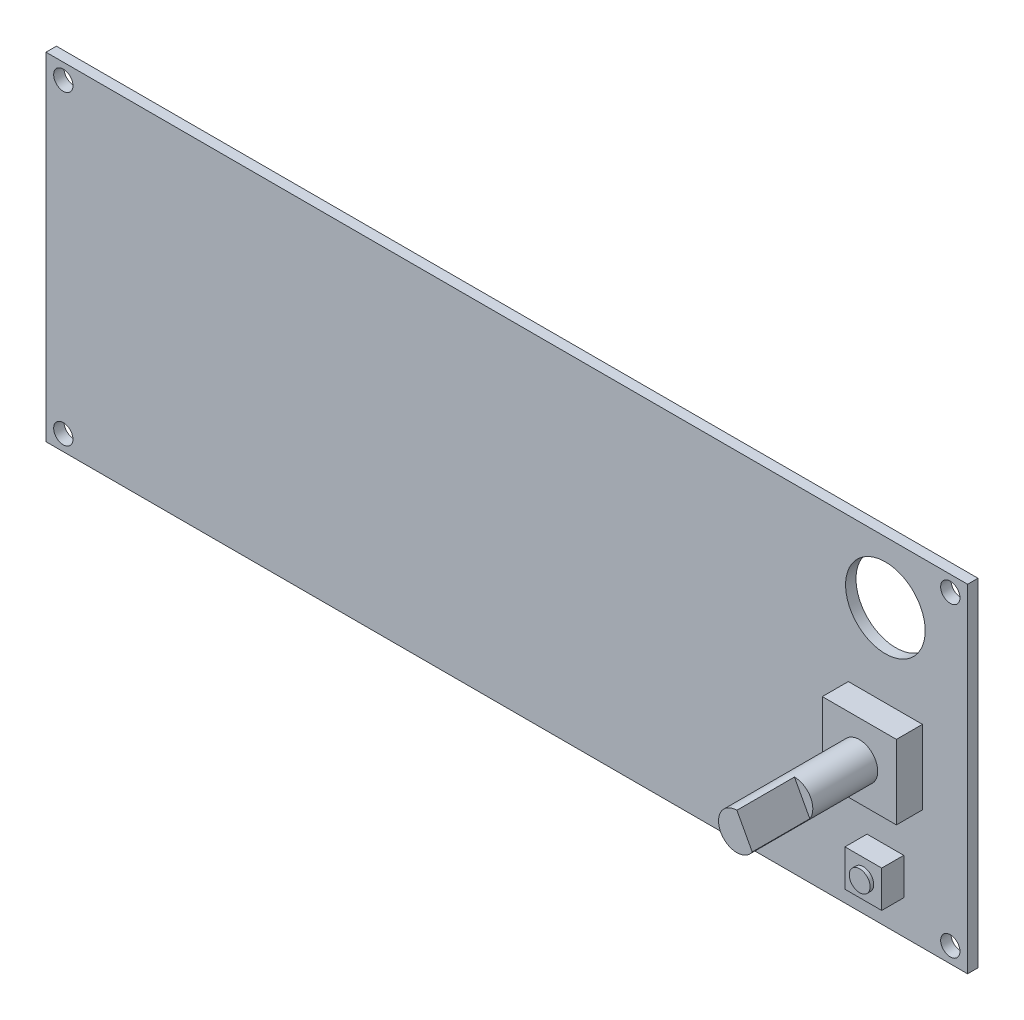
from build123d import *

# Parameters (mm, degrees)
SKETCH1_W                = 150.5
SKETCH1_H                = 55.1
SKETCH1_R                = 1.575
SKETCH1_R_2              = 6.5
SKETCH1_W_2              = 12.1
SKETCH1_H_2              = 12.1
SKETCH1_W_3              = 6
SKETCH1_H_3              = 6
BOSS_EXTRUDE1_DEPTH      = 1.7
SKETCH3_W                = 12.1
SKETCH3_H                = 12.1
BOSS_EXTRUDE2_DEPTH      = 4.25
BOSS_EXTRUDE2_DEPTH_BACK = 1.7
SKETCH5_R                = 3
BOSS_EXTRUDE3_DEPTH      = 20
CUT_EXTRUDE1_DEPTH       = 9.4
SKETCH7_W                = 6
SKETCH7_H                = 6
BOSS_EXTRUDE4_DEPTH      = 3.6
BOSS_EXTRUDE4_DEPTH_BACK = 1.7
SKETCH8_R                = 1.7
BOSS_EXTRUDE5_DEPTH      = 0.6
SKETCH9_W                = 26.4
SKETCH9_H                = 26.6
BOSS_EXTRUDE6_DEPTH      = 2.75
BOSS_EXTRUDE7_DEPTH      = 26.6
SKETCH11_W               = 2.263245578
SKETCH11_H               = 25.200228651
CUT_EXTRUDE2_DEPTH       = 25.75
SKETCH12_W               = 20.23176928
SKETCH12_H               = 8.8
SKETCH12_W_2             = 20.955499341
BOSS_EXTRUDE8_DEPTH      = 9
SKETCH13_W               = 17.717825076
SKETCH13_H               = 6.488260173
SKETCH13_W_2             = 18.921956069
CUT_EXTRUDE3_DEPTH       = 8


with BuildPart() as part:
    # Sketch1 → Boss-Extrude1 (new body)
    with BuildSketch(Plane.XY):
        Rectangle(SKETCH1_W, SKETCH1_H)
        with Locations((-72.425, 25)):
            Circle(SKETCH1_R, mode=Mode.SUBTRACT)
        with Locations((72.425, 25)):
            Circle(SKETCH1_R, mode=Mode.SUBTRACT)
        with Locations((72.425, -25)):
            Circle(SKETCH1_R, mode=Mode.SUBTRACT)
        with Locations((-72.425, -25)):
            Circle(SKETCH1_R, mode=Mode.SUBTRACT)
        with Locations((61.825, 17.5)):
            Circle(SKETCH1_R_2, mode=Mode.SUBTRACT)
        with Locations((61.825, -2)):
            Rectangle(SKETCH1_W_2, SKETCH1_H_2, mode=Mode.SUBTRACT)
        with Locations((61.825, -19)):
            Rectangle(SKETCH1_W_3, SKETCH1_H_3, mode=Mode.SUBTRACT)
    extrude(amount=-BOSS_EXTRUDE1_DEPTH)

    # Sketch3 → Boss-Extrude2 (add, two sides)
    with BuildSketch(Plane.XY) as boss_extrude2_sk:
        with Locations((61.825, -2)):
            Rectangle(SKETCH3_W, SKETCH3_H)
    extrude(amount=BOSS_EXTRUDE2_DEPTH)
    extrude(boss_extrude2_sk.sketch, amount=-BOSS_EXTRUDE2_DEPTH_BACK)

    # Sketch5 → Boss-Extrude3 (add)
    with BuildSketch(Plane.XY.offset(4.25)):
        with Locations((61.825, -2)):
            Circle(SKETCH5_R)
    extrude(amount=BOSS_EXTRUDE3_DEPTH)

    # Sketch6 → Cut-Extrude1 (cut)
    with BuildSketch(Plane.XY.offset(24.25)):
        Polygon((61.825, 1), (64.333206892, -3.645873077), (66.484499698, -3.318483035), (63.123279269, 3.423164798), align=None)
    extrude(amount=-CUT_EXTRUDE1_DEPTH, mode=Mode.SUBTRACT)

    # Sketch7 → Boss-Extrude4 (add, two sides)
    with BuildSketch(Plane.XY) as boss_extrude4_sk:
        with Locations((61.825, -19)):
            Rectangle(SKETCH7_W, SKETCH7_H)
    extrude(amount=BOSS_EXTRUDE4_DEPTH)
    extrude(boss_extrude4_sk.sketch, amount=-BOSS_EXTRUDE4_DEPTH_BACK)

    # Sketch8 → Boss-Extrude5 (add)
    with BuildSketch(Plane.XY.offset(3.6)):
        with Locations((61.825, -19)):
            Circle(SKETCH8_R)
    extrude(amount=BOSS_EXTRUDE5_DEPTH)

    # Sketch9 → Boss-Extrude6 (add)
    with BuildSketch(Plane(origin=(0, 0, -1.7), x_dir=(-1, 0, 0), z_dir=(0, 0, -1))):
        with Locations((62.05, -5.65)):
            Rectangle(SKETCH9_W, SKETCH9_H)
    extrude(amount=BOSS_EXTRUDE6_DEPTH)

    # Sketch10 → Boss-Extrude7 (add)
    with BuildSketch(Plane(origin=(0, 7.65, 0), x_dir=(1, 0, 0), z_dir=(0, 1, 0))):
        Polygon((-75.25, 4.45), (-75.25, 4.95), (-73.05, 4.45), align=None)
    extrude(amount=-BOSS_EXTRUDE7_DEPTH)

    # Sketch11 → Cut-Extrude2 (cut)
    with BuildSketch(Plane.ZY.offset(75.25)):
        with Locations((-3.161622789, -5.606749437)):
            Rectangle(SKETCH11_W, SKETCH11_H)
    extrude(amount=-CUT_EXTRUDE2_DEPTH, mode=Mode.SUBTRACT)

    # Sketch12 → Boss-Extrude8 (add)
    with BuildSketch(Plane(origin=(0, 0, -1.7), x_dir=(-1, 0, 0), z_dir=(0, 0, -1))):
        with Locations((-3.13411536, -7.1)):
            Rectangle(SKETCH12_W, SKETCH12_H)
        with Locations((19.77225033, -7.1)):
            Rectangle(SKETCH12_W_2, SKETCH12_H)
    extrude(amount=BOSS_EXTRUDE8_DEPTH)

    # Sketch13 → Cut-Extrude3 (cut)
    with BuildSketch(Plane.XZ.offset(11.5)):
        with Locations((3.496108, -6.088951298)):
            Rectangle(SKETCH13_W, SKETCH13_H)
        with Locations((-19.500417756, -6.088951298)):
            Rectangle(SKETCH13_W_2, SKETCH13_H)
    extrude(amount=-CUT_EXTRUDE3_DEPTH, mode=Mode.SUBTRACT)


solid = part.part
